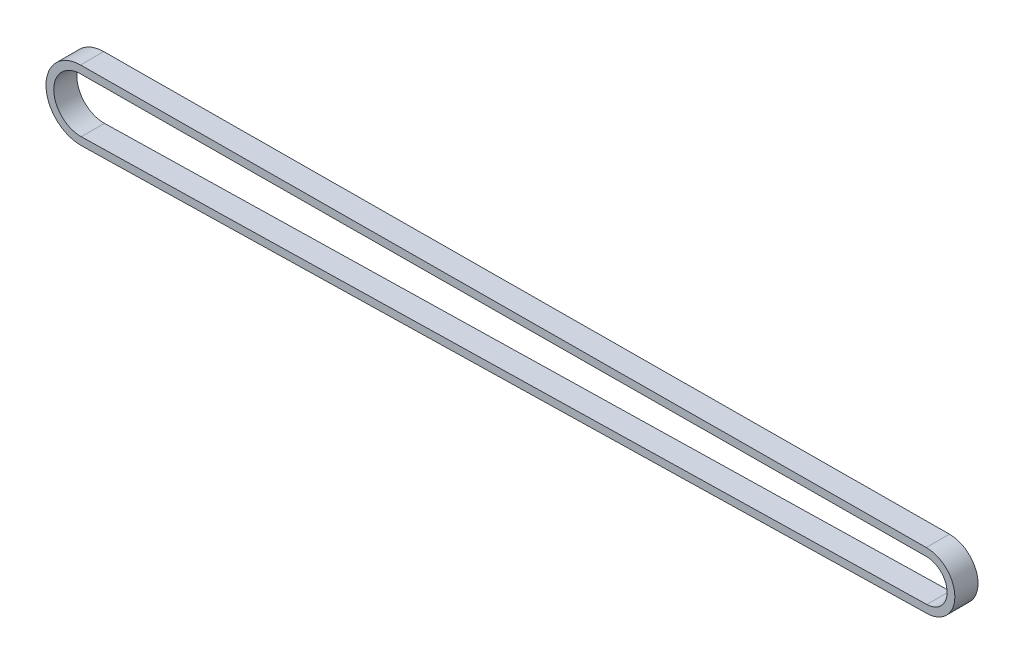
from build123d import *

# Parameters (mm, degrees)
BOSS_EXTRUDE1_DEPTH = 6


with BuildPart() as part:
    # Sketch1 → Boss-Extrude1 (new body)
    with BuildSketch(Plane.XY):
        with BuildLine():
            Line((110.47678504, -5.064979657), (-108.488832779, -9.638560963))
            ThreePointArc((-108.488832779, -9.638560963), (-117.675972692, -0.760820775), (-108.729420409, 8.359322473))
            Line((-108.729420409, 8.359322473), (110.280210153, 9.640397762))
            ThreePointArc((110.280210153, 9.640397762), (117.676119775, 2.385260391), (110.47678504, -5.064979657))
        make_face()
        with BuildLine():
            Line((-108.717721806, 6.359356688), (110.291908757, 7.640431976))
            ThreePointArc((110.291908757, 7.640431976), (115.676298442, 2.358527677), (110.435019726, -3.06541579))
            Line((110.435019726, -3.06541579), (-108.530598094, -7.638997096))
            ThreePointArc((-108.530598094, -7.638997096), (-115.676151359, -0.734088061), (-108.717721806, 6.359356688))
        make_face(mode=Mode.SUBTRACT)
    extrude(amount=BOSS_EXTRUDE1_DEPTH)


solid = part.part
